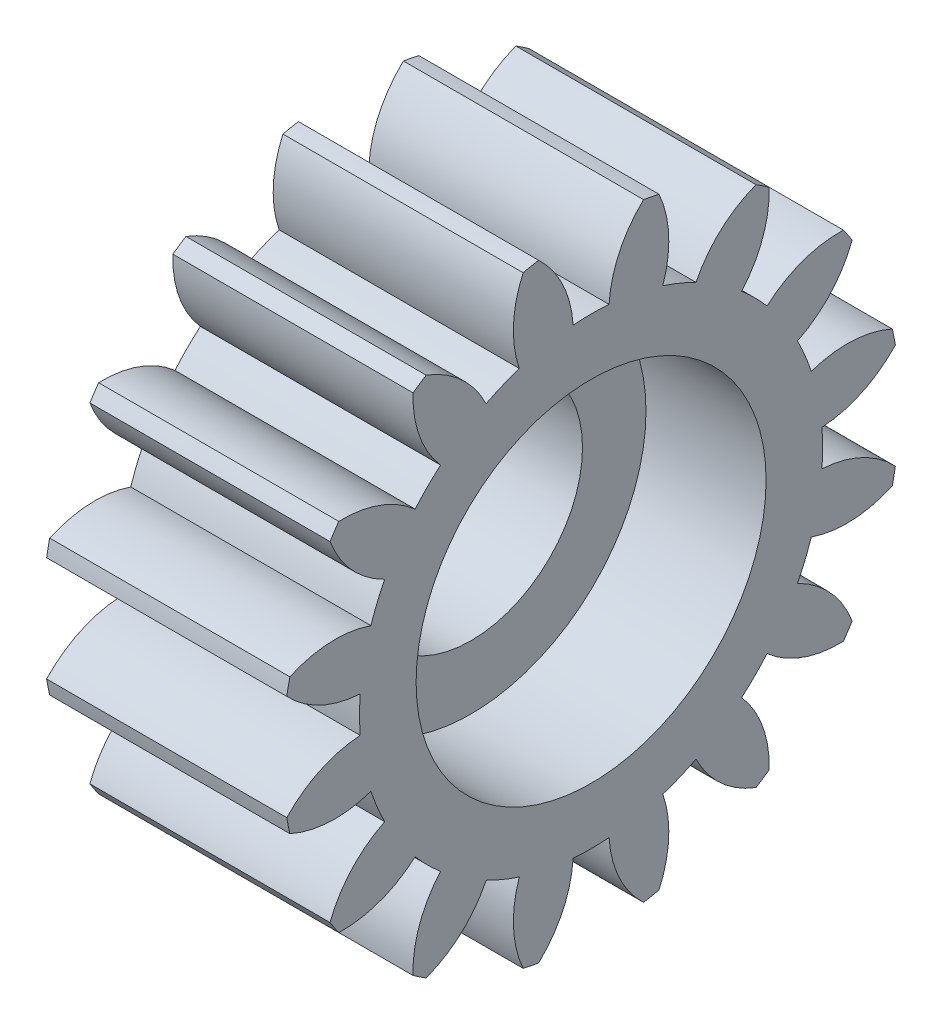
from build123d import *

# Parameters (mm, degrees)
ESQUISSE1_R             = 1.5
BOSS_EXTRU_1_DEPTH      = 7
ESQUISSE2_R             = 5.1
ENL_V_MAT_EXTRU_1_DEPTH = 3.5
ESQUISSE3_R             = 3.25
ENL_V_MAT_EXTRU_2_DEPTH = 4.5


with BuildPart() as part:
    # Esquisse1 → Boss.-Extru.1 (new body)
    with BuildSketch(Plane(origin=(7, 0, 0), x_dir=(0, 0, -1), z_dir=(1, 0, 0))):
        with BuildLine():
            ThreePointArc((-6.728643397, 0.523792937), (-6.749, 0), (-6.728643397, -0.523792937))
            ThreePointArc((-6.728643397, -0.523792937), (-7.89518869, -0.821876255), (-8.869006051, -1.529944991))
            ThreePointArc((-8.869006051, -1.529944991), (-8.827067524, -1.755812898), (-8.779377764, -1.980536814))
            ThreePointArc((-8.779377764, -1.980536814), (-7.608721662, -2.262043257), (-6.416902795, -2.091018776))
            ThreePointArc((-6.416902795, -2.091018776), (-6.235262965, -2.582730485), (-6.016009037, -3.058861924))
            ThreePointArc((-6.016009037, -3.058861924), (-6.97968481, -3.780672557), (-7.608408563, -4.80750654))
            ThreePointArc((-7.608408563, -4.80750654), (-7.483226511, -5.000132097), (-7.353168799, -5.189499843))
            ThreePointArc((-7.353168799, -5.189499843), (-6.163895735, -5.001587189), (-5.128246912, -4.387491836))
            ThreePointArc((-5.128246912, -4.387491836), (-4.772263666, -4.772263666), (-4.387491836, -5.128246912))
            ThreePointArc((-4.387491836, -5.128246912), (-5.001587189, -6.163895735), (-5.189499843, -7.353168799))
            ThreePointArc((-5.189499843, -7.353168799), (-5.000132097, -7.483226511), (-4.80750654, -7.608408563))
            ThreePointArc((-4.80750654, -7.608408563), (-3.780672557, -6.97968481), (-3.058861924, -6.016009037))
            ThreePointArc((-3.058861924, -6.016009037), (-2.582730485, -6.235262965), (-2.091018776, -6.416902795))
            ThreePointArc((-2.091018776, -6.416902795), (-2.262043257, -7.608721662), (-1.980536814, -8.779377764))
            ThreePointArc((-1.980536814, -8.779377764), (-1.755812898, -8.827067524), (-1.529944991, -8.869006051))
            ThreePointArc((-1.529944991, -8.869006051), (-0.821876255, -7.89518869), (-0.523792937, -6.728643397))
            ThreePointArc((-0.523792937, -6.728643397), (0, -6.749), (0.523792937, -6.728643397))
            ThreePointArc((0.523792937, -6.728643397), (0.821876255, -7.89518869), (1.529944991, -8.869006051))
            ThreePointArc((1.529944991, -8.869006051), (1.755812898, -8.827067524), (1.980536814, -8.779377764))
            ThreePointArc((1.980536814, -8.779377764), (2.262043257, -7.608721662), (2.091018776, -6.416902795))
            ThreePointArc((2.091018776, -6.416902795), (2.582730485, -6.235262965), (3.058861924, -6.016009037))
            ThreePointArc((3.058861924, -6.016009037), (3.780672557, -6.97968481), (4.80750654, -7.608408563))
            ThreePointArc((4.80750654, -7.608408563), (5.000132097, -7.483226511), (5.189499843, -7.353168799))
            ThreePointArc((5.189499843, -7.353168799), (5.001587189, -6.163895735), (4.387491836, -5.128246912))
            ThreePointArc((4.387491836, -5.128246912), (4.772263666, -4.772263666), (5.128246912, -4.387491836))
            ThreePointArc((5.128246912, -4.387491836), (6.163895735, -5.001587189), (7.353168799, -5.189499843))
            ThreePointArc((7.353168799, -5.189499843), (7.483226511, -5.000132097), (7.608408563, -4.80750654))
            ThreePointArc((7.608408563, -4.80750654), (6.97968481, -3.780672557), (6.016009037, -3.058861924))
            ThreePointArc((6.016009037, -3.058861924), (6.235262965, -2.582730485), (6.416902795, -2.091018776))
            ThreePointArc((6.416902795, -2.091018776), (7.608721662, -2.262043257), (8.779377764, -1.980536814))
            ThreePointArc((8.779377764, -1.980536814), (8.827067524, -1.755812898), (8.869006051, -1.529944991))
            ThreePointArc((8.869006051, -1.529944991), (7.89518869, -0.821876255), (6.728643397, -0.523792937))
            ThreePointArc((6.728643397, -0.523792937), (6.749, 0), (6.728643397, 0.523792937))
            ThreePointArc((6.728643397, 0.523792937), (7.89518869, 0.821876255), (8.869006051, 1.529944991))
            ThreePointArc((8.869006051, 1.529944991), (8.827067524, 1.755812898), (8.779377764, 1.980536814))
            ThreePointArc((8.779377764, 1.980536814), (7.608721662, 2.262043257), (6.416902795, 2.091018776))
            ThreePointArc((6.416902795, 2.091018776), (6.235262965, 2.582730485), (6.016009037, 3.058861924))
            ThreePointArc((6.016009037, 3.058861924), (6.97968481, 3.780672557), (7.608408563, 4.80750654))
            ThreePointArc((7.608408563, 4.80750654), (7.483226511, 5.000132097), (7.353168799, 5.189499843))
            ThreePointArc((7.353168799, 5.189499843), (6.163895735, 5.001587189), (5.128246912, 4.387491836))
            ThreePointArc((5.128246912, 4.387491836), (4.772263666, 4.772263666), (4.387491836, 5.128246912))
            ThreePointArc((4.387491836, 5.128246912), (5.001587189, 6.163895735), (5.189499843, 7.353168799))
            ThreePointArc((5.189499843, 7.353168799), (5.000132097, 7.483226511), (4.80750654, 7.608408563))
            ThreePointArc((4.80750654, 7.608408563), (3.780672557, 6.97968481), (3.058861924, 6.016009037))
            ThreePointArc((3.058861924, 6.016009037), (2.582730485, 6.235262965), (2.091018776, 6.416902795))
            ThreePointArc((2.091018776, 6.416902795), (2.262043257, 7.608721662), (1.980536814, 8.779377764))
            ThreePointArc((1.980536814, 8.779377764), (1.755812898, 8.827067524), (1.529944991, 8.869006051))
            ThreePointArc((1.529944991, 8.869006051), (0.821876255, 7.89518869), (0.523792937, 6.728643397))
            ThreePointArc((0.523792937, 6.728643397), (0, 6.749), (-0.523792937, 6.728643397))
            ThreePointArc((-0.523792937, 6.728643397), (-0.821876255, 7.89518869), (-1.529944991, 8.869006051))
            ThreePointArc((-1.529944991, 8.869006051), (-1.755812898, 8.827067524), (-1.980536814, 8.779377764))
            ThreePointArc((-1.980536814, 8.779377764), (-2.262043257, 7.608721662), (-2.091018776, 6.416902795))
            ThreePointArc((-2.091018776, 6.416902795), (-2.582730485, 6.235262965), (-3.058861924, 6.016009037))
            ThreePointArc((-3.058861924, 6.016009037), (-3.780672557, 6.97968481), (-4.80750654, 7.608408563))
            ThreePointArc((-4.80750654, 7.608408563), (-5.000132097, 7.483226511), (-5.189499843, 7.353168799))
            ThreePointArc((-5.189499843, 7.353168799), (-5.001587189, 6.163895735), (-4.387491836, 5.128246912))
            ThreePointArc((-4.387491836, 5.128246912), (-4.772263666, 4.772263666), (-5.128246912, 4.387491836))
            ThreePointArc((-5.128246912, 4.387491836), (-6.163895735, 5.001587189), (-7.353168799, 5.189499843))
            ThreePointArc((-7.353168799, 5.189499843), (-7.483226511, 5.000132097), (-7.608408563, 4.80750654))
            ThreePointArc((-7.608408563, 4.80750654), (-6.97968481, 3.780672557), (-6.016009037, 3.058861924))
            ThreePointArc((-6.016009037, 3.058861924), (-6.235262965, 2.582730485), (-6.416902795, 2.091018776))
            ThreePointArc((-6.416902795, 2.091018776), (-7.608721662, 2.262043257), (-8.779377764, 1.980536814))
            ThreePointArc((-8.779377764, 1.980536814), (-8.827067524, 1.755812898), (-8.869006051, 1.529944991))
            ThreePointArc((-8.869006051, 1.529944991), (-7.89518869, 0.821876255), (-6.728643397, 0.523792937))
        make_face()
        Circle(ESQUISSE1_R, mode=Mode.SUBTRACT)
    extrude(amount=-BOSS_EXTRU_1_DEPTH)

    # Esquisse2 → Enlèv. mat.-Extru.1 (cut)
    with BuildSketch(Plane(origin=(7, 0, 0), x_dir=(0, 0, -1), z_dir=(1, 0, 0))):
        Circle(ESQUISSE2_R)
    extrude(amount=-ENL_V_MAT_EXTRU_1_DEPTH, mode=Mode.SUBTRACT)

    # Esquisse3 → Enlèv. mat.-Extru.2 (cut, through all)
    with BuildSketch(Plane(origin=(3.5, 0, 0), x_dir=(0, 0, -1), z_dir=(1, 0, 0))):
        Circle(ESQUISSE3_R)
    extrude(amount=-ENL_V_MAT_EXTRU_2_DEPTH, mode=Mode.SUBTRACT)


solid = part.part
